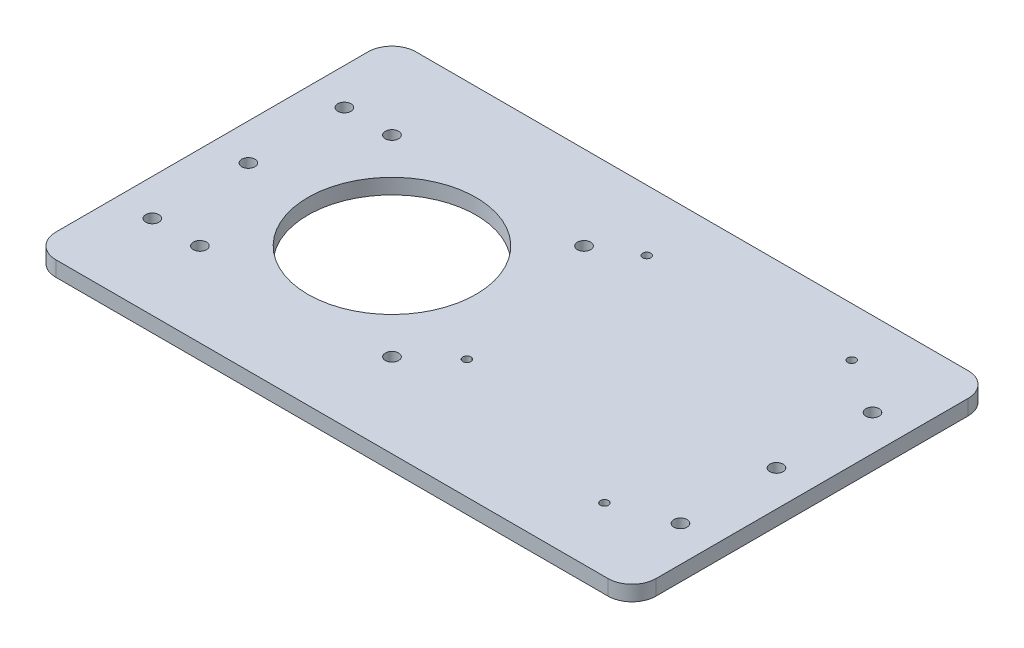
from build123d import *

# Parameters (mm, degrees)
SKETCH1_W                                       = 250
SKETCH1_H                                       = 150
BOSS_EXTRUDE1_DEPTH                             = 6.35
SKETCH2_R                                       = 35
SKETCH2_R_2                                     = 2.75
CUT_EXTRUDE1_DEPTH                              = 7.35
FILLET1_R                                       = 10
CSK_FOR_M5_FLAT_HEAD_MACHINE_SCREW1_D           = 5.5
CSK_FOR_M5_FLAT_HEAD_MACHINE_SCREW1_CSINK_D     = 10.4
CSK_FOR_M5_FLAT_HEAD_MACHINE_SCREW1_CSINK_ANGLE = 90
CSK_FOR_M3_FLAT_HEAD_MACHINE_SCREW1_D           = 3.4
CSK_FOR_M3_FLAT_HEAD_MACHINE_SCREW1_CSINK_D     = 6.3
CSK_FOR_M3_FLAT_HEAD_MACHINE_SCREW1_CSINK_ANGLE = 90


with BuildPart() as part:
    # Sketch1 → Boss-Extrude1 (new body)
    with BuildSketch(Plane(origin=(0, 0, 0), x_dir=(1, 0, 0), z_dir=(0, 1, 0))):
        with Locations((50, 0)):
            Rectangle(SKETCH1_W, SKETCH1_H)
    extrude(amount=BOSS_EXTRUDE1_DEPTH)

    # Sketch2 → Cut-Extrude1 (cut, through all)
    with BuildSketch(Plane(origin=(0, 6.35, 0), x_dir=(1, 0, 0), z_dir=(0, 1, 0))):
        Circle(SKETCH2_R)
        with Locations((-40, 40)):
            Circle(SKETCH2_R_2)
        with Locations((40, 40)):
            Circle(SKETCH2_R_2)
        with Locations((-40, -40)):
            Circle(SKETCH2_R_2)
        with Locations((40, -40)):
            Circle(SKETCH2_R_2)
    extrude(amount=-CUT_EXTRUDE1_DEPTH, mode=Mode.SUBTRACT)

    # Fillet1
    fillet1_edges = [part.edges().sort_by_distance(p)[0] for p in [
        (-75, 3.175, -75),
        (175, 3.175, -75),
        (175, 3.175, 75),
        (-75, 3.175, 75),
    ]]
    fillet(fillet1_edges, radius=FILLET1_R)

    # CSK for M5 Flat Head Machine Screw1 (through all)
    with Locations(Plane(origin=(0, 0, 0), x_dir=(-1, 0, 0), z_dir=(0, -1, 0))):
        with Locations((59.828254494, 40), (59.828254494, 0), (59.828254494, -40), (-160.171745506, 40), (-160.171745506, 0), (-160.171745506, -40)):
            CounterSinkHole(CSK_FOR_M5_FLAT_HEAD_MACHINE_SCREW1_D / 2, CSK_FOR_M5_FLAT_HEAD_MACHINE_SCREW1_CSINK_D / 2, counter_sink_angle=CSK_FOR_M5_FLAT_HEAD_MACHINE_SCREW1_CSINK_ANGLE)

    # CSK for M3 Flat Head Machine Screw1 (through all)
    with Locations(Plane(origin=(0, 0, 0), x_dir=(-1, 0, 0), z_dir=(0, -1, 0))):
        with Locations((-136.964698881, -48.452177006), (-56.504698881, -25.286715777), (-56.504698881, 49.613284223), (-136.964698881, 54.547822994)):
            CounterSinkHole(CSK_FOR_M3_FLAT_HEAD_MACHINE_SCREW1_D / 2, CSK_FOR_M3_FLAT_HEAD_MACHINE_SCREW1_CSINK_D / 2, counter_sink_angle=CSK_FOR_M3_FLAT_HEAD_MACHINE_SCREW1_CSINK_ANGLE)


solid = part.part
